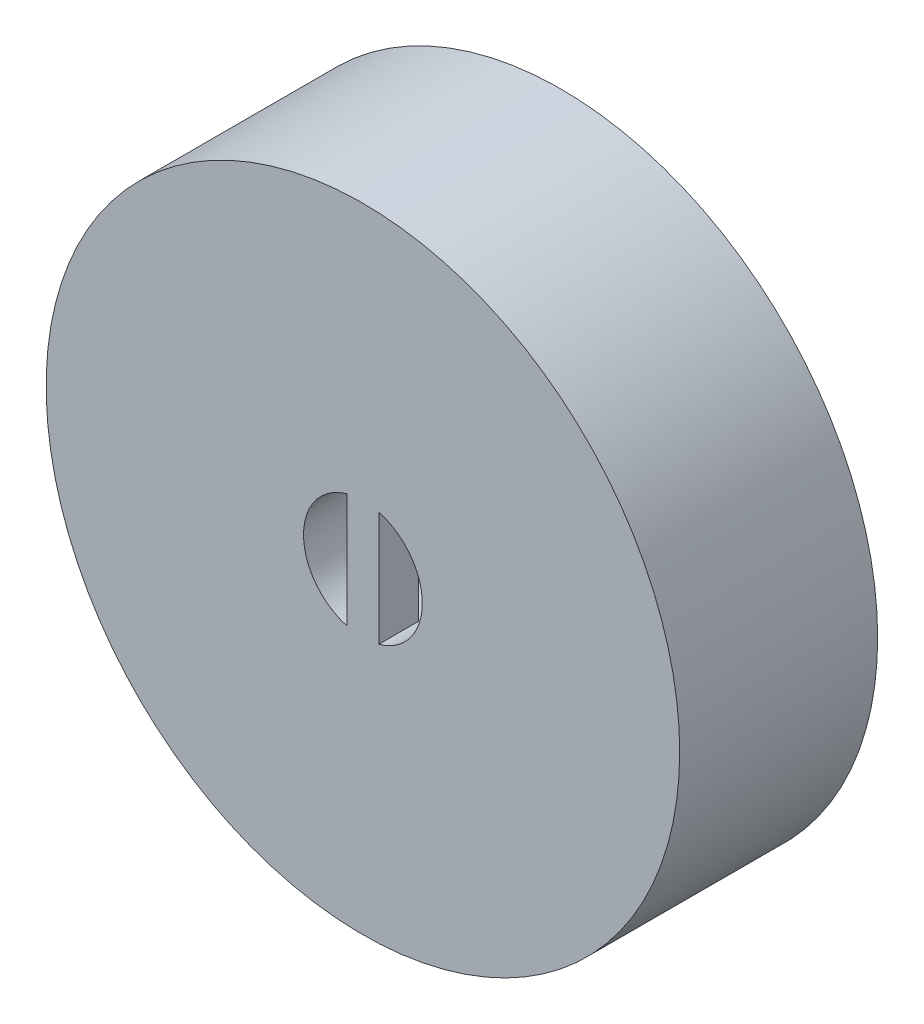
from build123d import *

# Parameters (mm, degrees)
SKETCH1_R           = 25.4
SKETCH1_R_2         = 4.7625
BOSS_EXTRUDE1_DEPTH = 15.875
BOSS_EXTRUDE2_START = -9.525
SKETCH1_3_R         = 9.525
SKETCH1_3_R_2       = 4.7625
BOSS_EXTRUDE2_DEPTH = 9.525
FILLET1_R           = 2.54
BOSS_EXTRUDE3_START = -3.175
BOSS_EXTRUDE3_DEPTH = 3.175


with BuildPart() as part:
    # Sketch1 → Boss-Extrude1 (new body)
    with BuildSketch(Plane.XY):
        Circle(SKETCH1_R)
        Circle(SKETCH1_R_2, mode=Mode.SUBTRACT)
    extrude(amount=BOSS_EXTRUDE1_DEPTH)

    # Sketch1_3 → Boss-Extrude2 (add)
    with BuildSketch(Plane.XY.offset(BOSS_EXTRUDE2_START)):
        Circle(SKETCH1_3_R)
        Circle(SKETCH1_3_R_2, mode=Mode.SUBTRACT)
    extrude(amount=BOSS_EXTRUDE2_DEPTH)

    # Fillet1
    fillet1_edges = [part.edges().sort_by_distance(p)[0] for p in [
        (-9.525, 0, 0),
    ]]
    fillet(fillet1_edges, radius=FILLET1_R)

    # Sketch2 → Boss-Extrude3 (add)
    with BuildSketch(Plane.XY.offset(15.875).offset(BOSS_EXTRUDE3_START)):
        with BuildLine():
            Line((-1.27, 4.590044254), (-1.27, -4.590044254))
            ThreePointArc((-1.27, -4.590044254), (0, -4.7625), (1.27, -4.590044254))
            Line((1.27, -4.590044254), (1.27, 4.590044254))
            ThreePointArc((1.27, 4.590044254), (0, 4.7625), (-1.27, 4.590044254))
        make_face()
    extrude(amount=BOSS_EXTRUDE3_DEPTH)


solid = part.part
